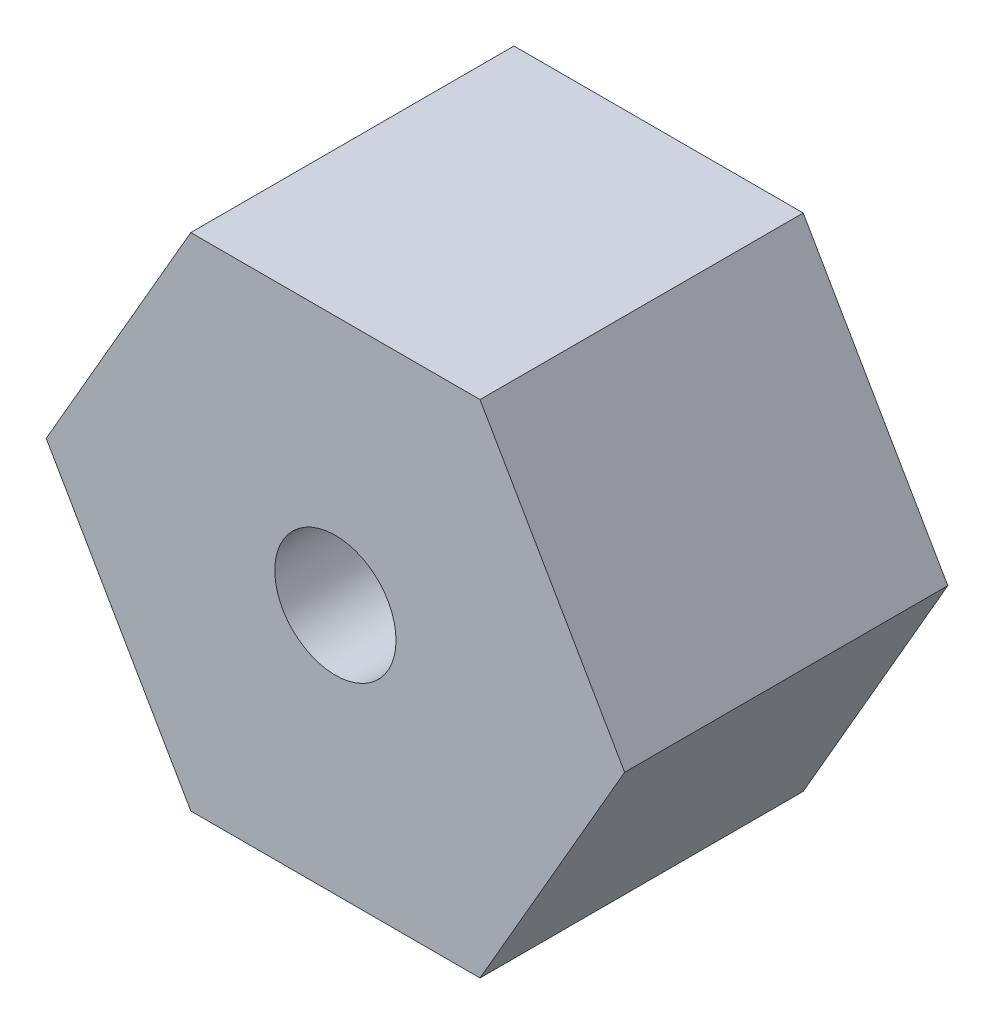
from build123d import *

# Parameters (mm, degrees)
SKETCH1_R  = 1.5
MAIN_DEPTH = 8


with BuildPart() as part:
    # Sketch1 → Main (new body)
    with BuildSketch(Plane.XY):
        Polygon((-3.579571669, 6.2), (3.579571669, 6.2), (7.159143338, 0), (3.579571669, -6.2), (-3.579571669, -6.2), (-7.159143338, 0), align=None)
        Circle(SKETCH1_R, mode=Mode.SUBTRACT)
    extrude(amount=MAIN_DEPTH)


solid = part.part
